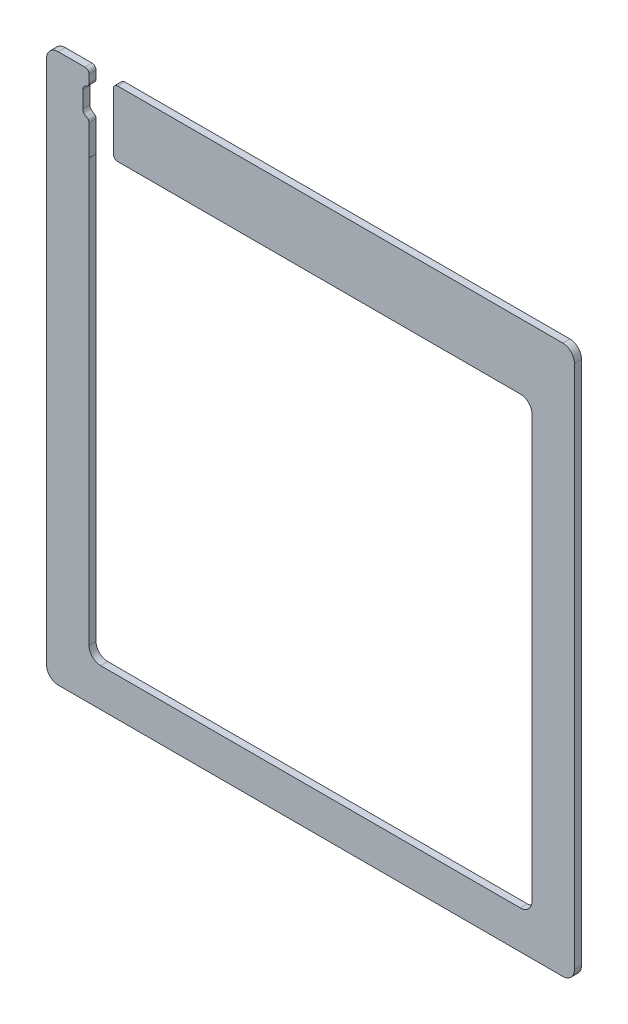
from build123d import *

# Parameters (mm, degrees)
SKETCH1_W           = 323.85
SKETCH1_H           = 336.55
BOSS_EXTRUDE1_DEPTH = 4.3434
SKETCH2_W           = 271.78
SKETCH2_H           = 273.05
CUT_EXTRUDE1_DEPTH  = 5.3434
FILLET1_R           = 7.14375
CUT_EXTRUDE2_DEPTH  = 5.3434
SKETCH4_W           = 14.979655554
SKETCH4_H           = 46.925096095
CUT_EXTRUDE3_DEPTH  = 5.3434
FILLET2_R           = 2.54


with BuildPart() as part:
    # Sketch1 → Boss-Extrude1 (new body)
    with BuildSketch(Plane.XY):
        Rectangle(SKETCH1_W, SKETCH1_H)
    extrude(amount=BOSS_EXTRUDE1_DEPTH)

    # Sketch2 → Cut-Extrude1 (cut, through all)
    with BuildSketch(Plane.XY.offset(4.3434)):
        with Locations((0, -8.382)):
            Rectangle(SKETCH2_W, SKETCH2_H)
    extrude(amount=-CUT_EXTRUDE1_DEPTH, mode=Mode.SUBTRACT)

    # Fillet1
    fillet1_edges = [part.edges().sort_by_distance(p)[0] for p in [
        (135.89, 128.143, 2.1717),
        (135.89, -144.907, 2.1717),
        (-135.89, -144.907, 2.1717),
        (-135.89, 128.143, 2.1717),
        (161.925, -168.275, 2.1717),
        (-161.925, -168.275, 2.1717),
        (-161.925, 168.275, 2.1717),
        (161.925, 168.275, 2.1717),
    ]]
    fillet(fillet1_edges, radius=FILLET1_R)

    # Sketch3 → Cut-Extrude2 (cut, through all)
    with BuildSketch(Plane.XY.offset(4.3434)):
        with BuildLine():
            Line((-139.7, 145.415), (-139.7, 155.575))
            ThreePointArc((-139.7, 155.575), (-136.525, 158.75), (-133.35, 155.575))
            Line((-133.35, 155.575), (-133.35, 145.415))
            ThreePointArc((-133.35, 145.415), (-136.525, 142.24), (-139.7, 145.415))
        make_face()
    extrude(amount=-CUT_EXTRUDE2_DEPTH, mode=Mode.SUBTRACT)

    # Sketch4 → Cut-Extrude3 (cut, through all)
    with BuildSketch(Plane.XY.offset(4.3434)):
        with Locations((-128.400172223, 144.812451952)):
            Rectangle(SKETCH4_W, SKETCH4_H)
    extrude(amount=-CUT_EXTRUDE3_DEPTH, mode=Mode.SUBTRACT)

    # Fillet2
    fillet2_edges = [part.edges().sort_by_distance(p)[0] for p in [
        (-120.910344446, 168.275, 2.1717),
        (-135.89, 142.304148027, 2.1717),
        (-135.89, 168.275, 2.1717),
        (-135.89, 158.685851973, 2.1717),
        (-120.910344446, 128.143, 2.1717),
    ]]
    fillet(fillet2_edges, radius=FILLET2_R)


solid = part.part
